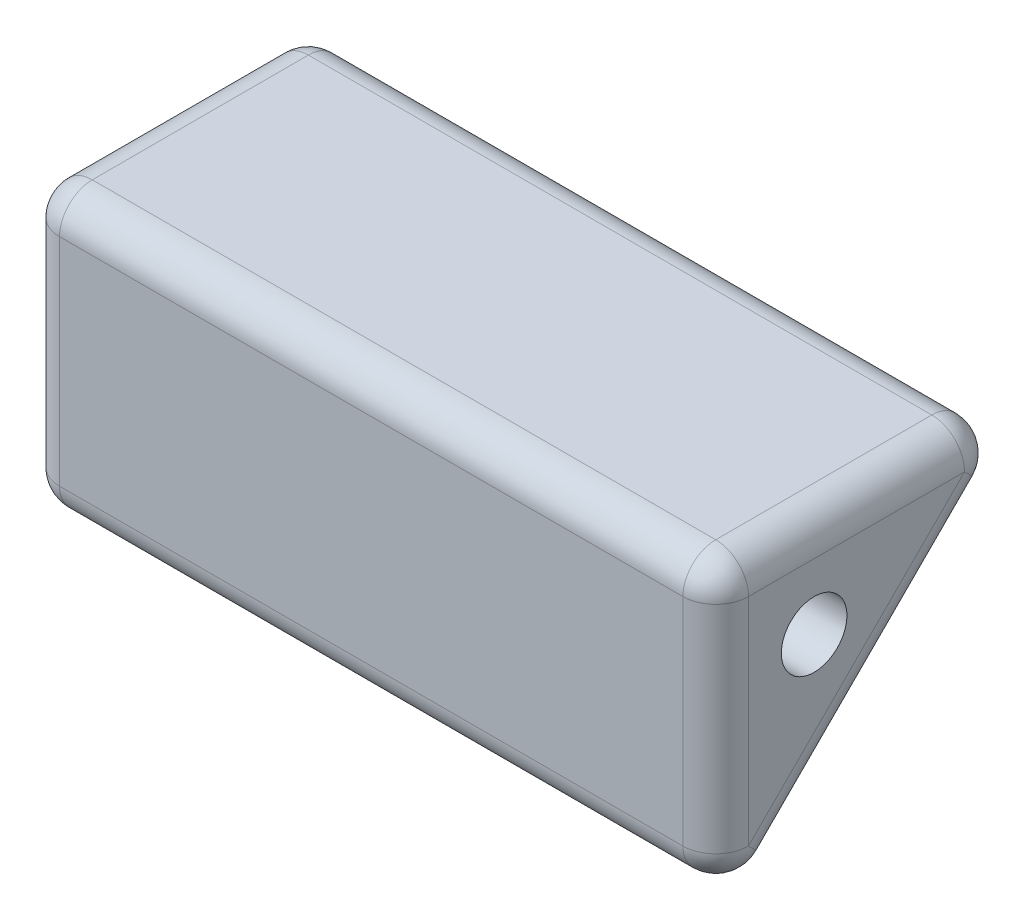
from build123d import *

# Parameters (mm, degrees)
BODY_DEPTH      = 21
SKETCH2_R       = 1
BOLT_HOLE_DEPTH = 22
EDGE_FILLETS_R  = 1


with BuildPart() as part:
    # Sketch1 → body (new body)
    with BuildSketch(Plane(origin=(0, 0, 0), x_dir=(0, 0, -1), z_dir=(1, 0, 0))):
        Polygon((0, 0), (10, 0), (0, -10), align=None)
    extrude(amount=BODY_DEPTH)

    # Sketch2 → bolt_hole (cut, through all)
    with BuildSketch(Plane.ZY):
        with Locations((-3, -3)):
            Circle(SKETCH2_R)
    extrude(amount=-BOLT_HOLE_DEPTH, mode=Mode.SUBTRACT)

    # edge_fillets
    edge_fillets_edges = [part.edges().sort_by_distance(p)[0] for p in [
        (21, -5, 0),
        (21, -5, -5),
        (0, -5, -5),
        (0, -5, 0),
        (0, 0, -5),
        (21, 0, -5),
        (10.5, 0, -10),
        (10.5, -10, 0),
        (10.5, 0, 0),
    ]]
    fillet(edge_fillets_edges, radius=EDGE_FILLETS_R)


solid = part.part
